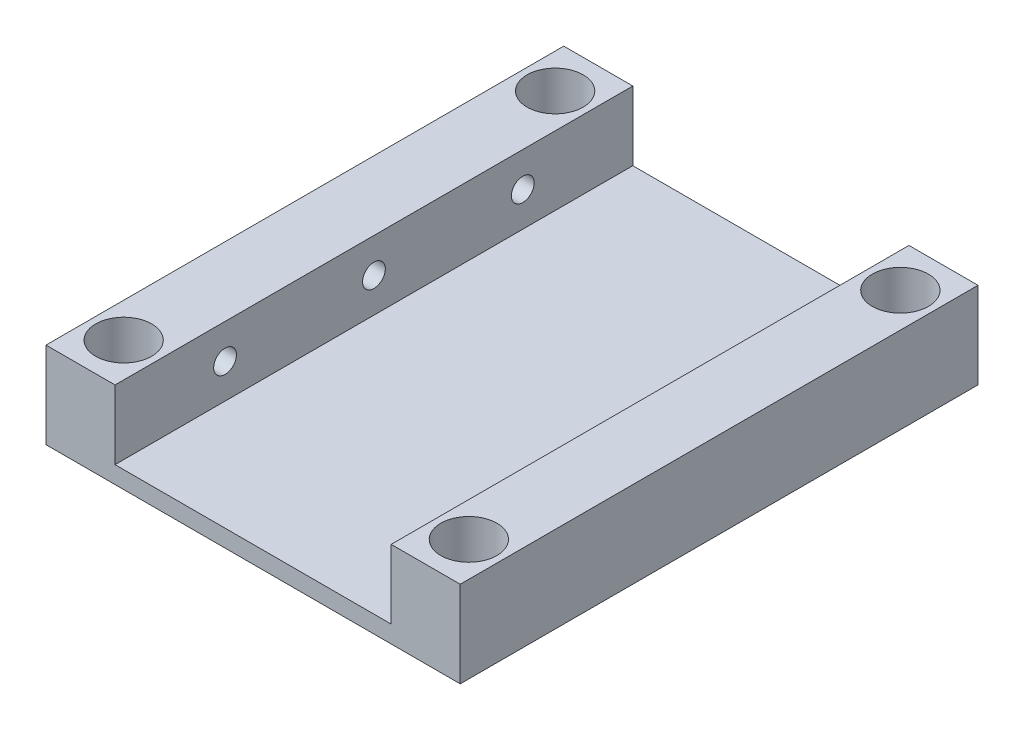
from build123d import *

# Parameters (mm, degrees)
BOSS_EXTRUDE1_DEPTH = 60
SKETCH3_R           = 3.25
CUT_EXTRUDE1_DEPTH  = 8
SKETCH4_R           = 2
CUT_EXTRUDE2_DEPTH  = 8
CUT_EXTRUDE3_REACH  = 50
SKETCH5_R           = 1.32
SKETCH6_R           = 3.25
CUT_EXTRUDE4_DEPTH  = 6


with BuildPart() as part:
    # Sketch1 → Boss-Extrude1 (new body)
    with BuildSketch(Plane.XY):
        Polygon((-48, 0), (-48, 10), (-40, 10), (-40, 2), (-8, 2), (-8, 10), (0, 10), (0, 0), align=None)
    extrude(amount=BOSS_EXTRUDE1_DEPTH)

    # Sketch3 → Cut-Extrude1 (cut)
    with BuildSketch(Plane(origin=(0, 10, 0), x_dir=(1, 0, 0), z_dir=(0, 1, 0))):
        with Locations((-44, -5)):
            Circle(SKETCH3_R)
        with Locations((-4, -5)):
            Circle(SKETCH3_R)
        with Locations((-4, -55)):
            Circle(SKETCH3_R)
        with Locations((-44, -55)):
            Circle(SKETCH3_R)
    extrude(amount=-CUT_EXTRUDE1_DEPTH, mode=Mode.SUBTRACT)

    # Sketch4 → Cut-Extrude2 (cut)
    with BuildSketch(Plane.XZ):
        with Locations((-44, 55)):
            Circle(SKETCH4_R)
        with Locations((-4, 55)):
            Circle(SKETCH4_R)
        with Locations((-4, 5)):
            Circle(SKETCH4_R)
        with Locations((-44, 5)):
            Circle(SKETCH4_R)
    extrude(amount=-CUT_EXTRUDE2_DEPTH, mode=Mode.SUBTRACT)

    # Sketch5 → Cut-Extrude3 (cut, up to next)
    with BuildSketch(Plane.ZY.offset(48), mode=Mode.PRIVATE) as cut_extrude3_sk1:
        with Locations((12.75, 6)):
            Circle(SKETCH5_R)
    cut_extrude3_tool1 = extrude(cut_extrude3_sk1.sketch, amount=-CUT_EXTRUDE3_REACH, mode=Mode.PRIVATE) & part.part
    add(cut_extrude3_tool1.solids().sort_by_distance((-48, 6, 12.75))[0], mode=Mode.SUBTRACT)
    # Sketch5 → Cut-Extrude3 (cut, up to next)
    with BuildSketch(Plane.ZY.offset(48), mode=Mode.PRIVATE) as cut_extrude3_sk2:
        with Locations((30, 6)):
            Circle(SKETCH5_R)
    cut_extrude3_tool2 = extrude(cut_extrude3_sk2.sketch, amount=-CUT_EXTRUDE3_REACH, mode=Mode.PRIVATE) & part.part
    add(cut_extrude3_tool2.solids().sort_by_distance((-48, 6, 30))[0], mode=Mode.SUBTRACT)
    # Sketch5 → Cut-Extrude3 (cut, up to next)
    with BuildSketch(Plane.ZY.offset(48), mode=Mode.PRIVATE) as cut_extrude3_sk3:
        with Locations((47.25, 6)):
            Circle(SKETCH5_R)
    cut_extrude3_tool3 = extrude(cut_extrude3_sk3.sketch, amount=-CUT_EXTRUDE3_REACH, mode=Mode.PRIVATE) & part.part
    add(cut_extrude3_tool3.solids().sort_by_distance((-48, 6, 47.25))[0], mode=Mode.SUBTRACT)

    # Sketch6 → Cut-Extrude4 (cut)
    with BuildSketch(Plane.ZY.offset(48)):
        with Locations((12.75, 6)):
            Circle(SKETCH6_R)
        with Locations((30, 6)):
            Circle(SKETCH6_R)
        with Locations((47.25, 6)):
            Circle(SKETCH6_R)
    extrude(amount=-CUT_EXTRUDE4_DEPTH, mode=Mode.SUBTRACT)


solid = part.part
